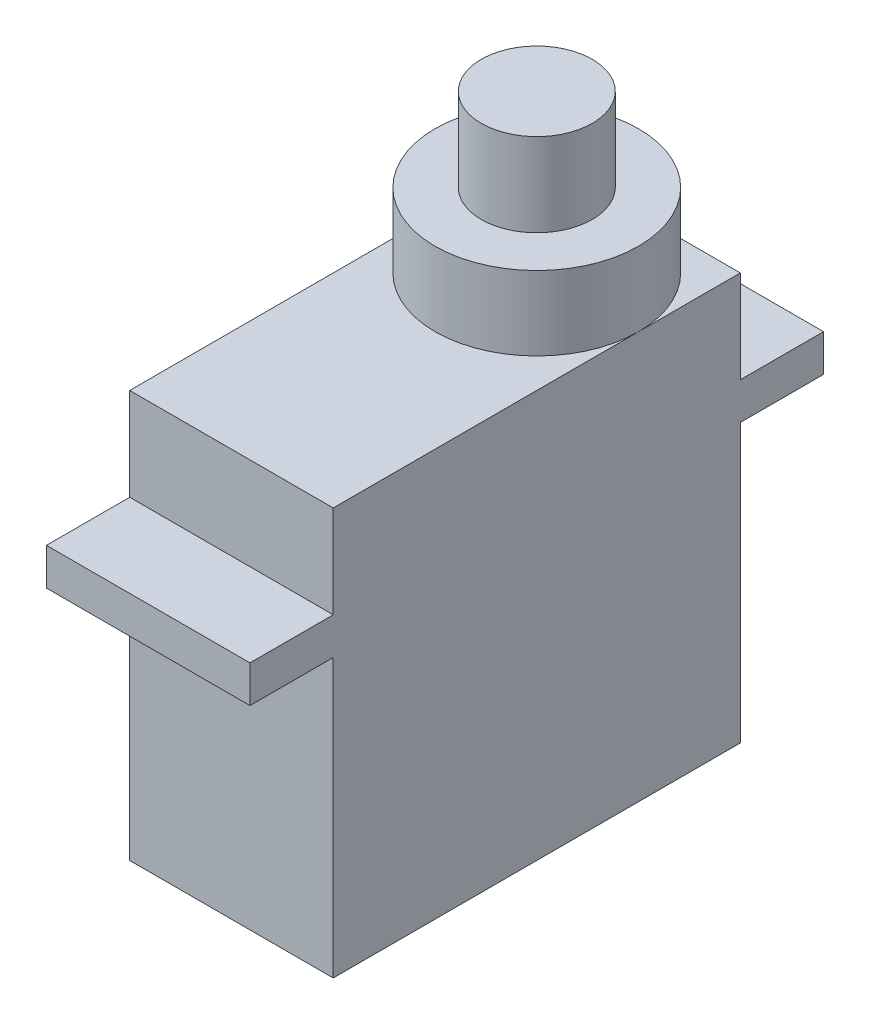
from build123d import *

# Parameters (mm, degrees)
SKETCH2_W           = 11
SKETCH2_H           = 22
BOSS_EXTRUDE1_DEPTH = 22
SKETCH3_W           = 11
SKETCH3_H           = 4.5
BOSS_EXTRUDE2_DEPTH = 2
SKETCH4_R           = 5.5
BOSS_EXTRUDE3_DEPTH = 4
SKETCH5_R           = 3
BOSS_EXTRUDE4_DEPTH = 4.5


with BuildPart() as part:
    # Sketch2 → Boss-Extrude1 (new body)
    with BuildSketch(Plane(origin=(0, 0, 0), x_dir=(1, 0, 0), z_dir=(0, 1, 0))):
        Rectangle(SKETCH2_W, SKETCH2_H)
    extrude(amount=BOSS_EXTRUDE1_DEPTH)

    # Sketch3 → Boss-Extrude2 (add)
    with BuildSketch(Plane(origin=(0, 15, 0), x_dir=(1, 0, 0), z_dir=(0, 1, 0))):
        with Locations((0, 13.25)):
            Rectangle(SKETCH3_W, SKETCH3_H)
        with Locations((0, -13.25)):
            Rectangle(SKETCH3_W, SKETCH3_H)
    extrude(amount=BOSS_EXTRUDE2_DEPTH)

    # Sketch4 → Boss-Extrude3 (add)
    with BuildSketch(Plane(origin=(0, 22, 0), x_dir=(1, 0, 0), z_dir=(0, 1, 0))):
        with Locations((0, 5.5)):
            Circle(SKETCH4_R)
    extrude(amount=BOSS_EXTRUDE3_DEPTH)

    # Sketch5 → Boss-Extrude4 (add)
    with BuildSketch(Plane(origin=(0, 26, 0), x_dir=(1, 0, 0), z_dir=(0, 1, 0))):
        with Locations((0, 5.5)):
            Circle(SKETCH5_R)
    extrude(amount=BOSS_EXTRUDE4_DEPTH)


solid = part.part
